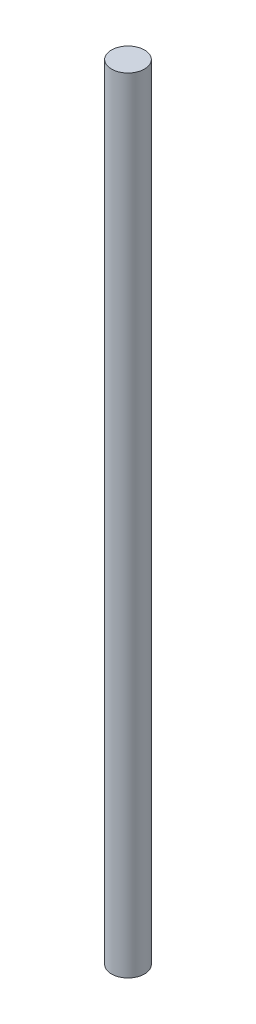
from build123d import *

# Parameters (mm, degrees)
SKETCH1_R           = 1.4732
BOSS_EXTRUDE1_DEPTH = 69.85


with BuildPart() as part:
    # Sketch1 → Boss-Extrude1 (new body)
    with BuildSketch(Plane(origin=(0, 0, 0), x_dir=(1, 0, 0), z_dir=(0, 1, 0))):
        Circle(SKETCH1_R)
    extrude(amount=BOSS_EXTRUDE1_DEPTH)


solid = part.part
